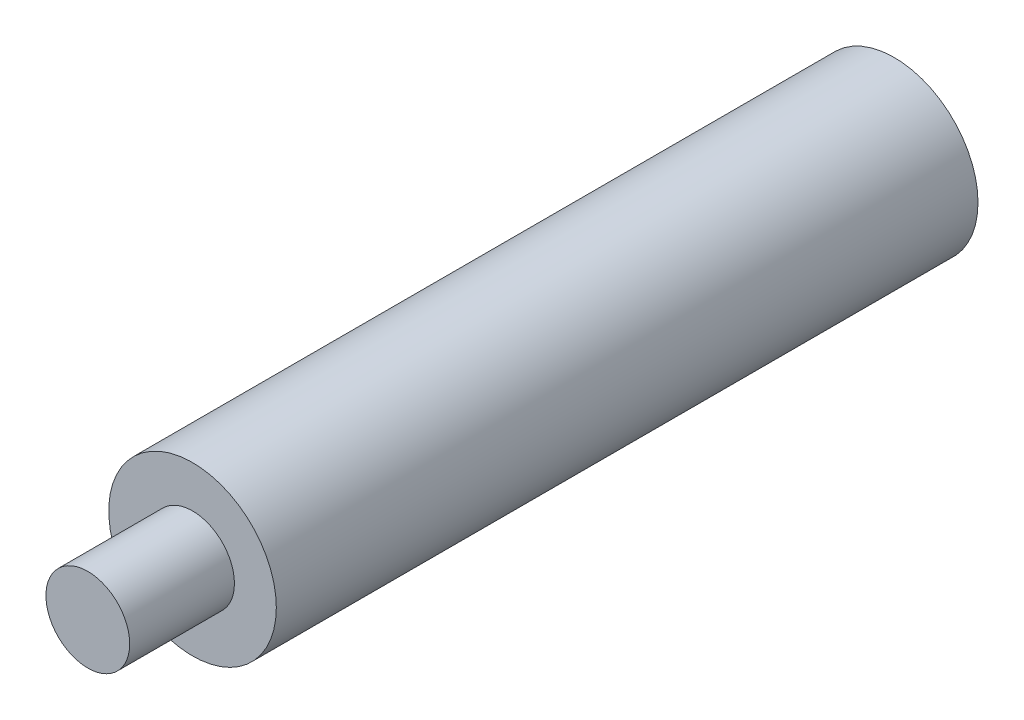
from build123d import *

# Parameters (mm, degrees)
SKETCH1_R           = 4
BOSS_EXTRUDE1_DEPTH = 33.5
SKETCH2_R           = 2
BOSS_EXTRUDE2_DEPTH = 5
SKETCH3_R           = 1.5
CUT_EXTRUDE1_DEPTH  = 10


with BuildPart() as part:
    # Sketch1 → Boss-Extrude1 (new body)
    with BuildSketch(Plane.XY):
        Circle(SKETCH1_R)
    extrude(amount=BOSS_EXTRUDE1_DEPTH)

    # Sketch2 → Boss-Extrude2 (add)
    with BuildSketch(Plane.XY.offset(33.5)):
        Circle(SKETCH2_R)
    extrude(amount=BOSS_EXTRUDE2_DEPTH)

    # Sketch3 → Cut-Extrude1 (cut)
    with BuildSketch(Plane(origin=(0, 0, 0), x_dir=(-1, 0, 0), z_dir=(0, 0, -1))):
        Circle(SKETCH3_R)
    extrude(amount=-CUT_EXTRUDE1_DEPTH, mode=Mode.SUBTRACT)


solid = part.part
